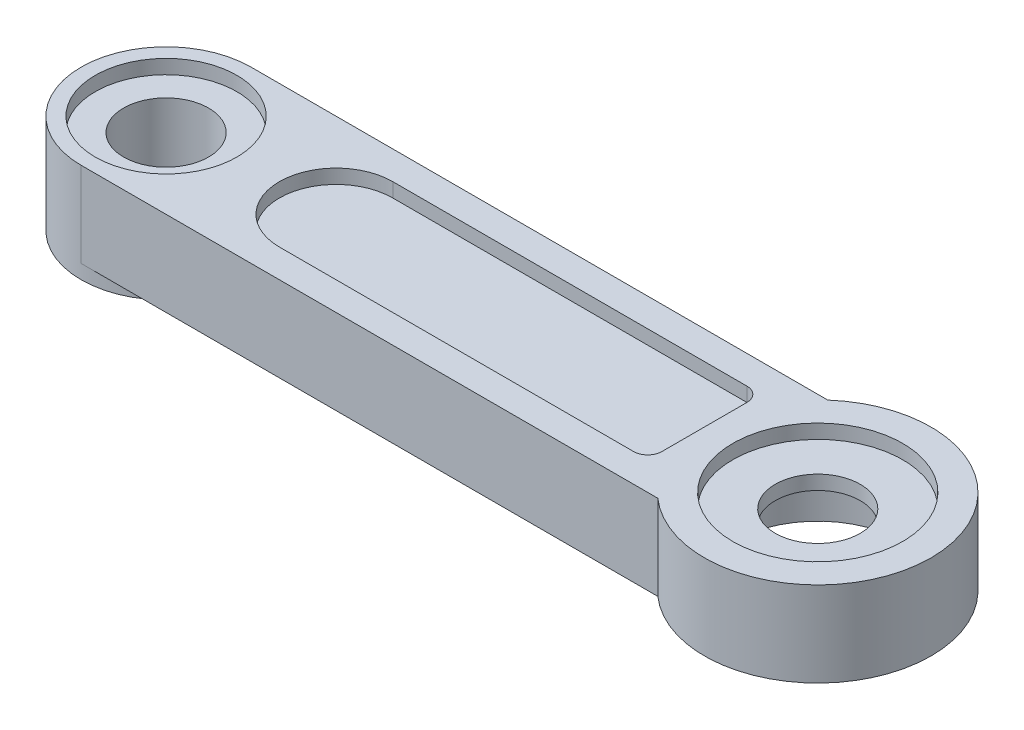
from build123d import *

# Parameters (mm, degrees)
SKETCH1_R           = 4
BOSS_EXTRUDE1_DEPTH = 3
SKETCH5_W           = 23
SKETCH5_H           = 6
BOSS_EXTRUDE2_DEPTH = 3
SKETCH2_R           = 3
CUT_EXTRUDE4_DEPTH  = 0.5
SKETCH7_R           = 1.5
CUT_EXTRUDE5_DEPTH  = 3.5
SKETCH8_R           = 3
CUT_EXTRUDE7_DEPTH  = 2
SKETCH9_R           = 3
BOSS_EXTRUDE3_DEPTH = 3
SKETCH10_R          = 2.5
CUT_EXTRUDE8_DEPTH  = 0.5
CUT_EXTRUDE10_DEPTH = 0.5
CUT_EXTRUDE11_DEPTH = 0.5
SKETCH11_R          = 3
BOSS_EXTRUDE5_DEPTH = 0.5
SKETCH15_R          = 1.5
CUT_EXTRUDE12_DEPTH = 4


with BuildPart() as part:
    # Sketch1 → Boss-Extrude1 (new body)
    with BuildSketch(Plane(origin=(0, 0, 0), x_dir=(1, 0, 0), z_dir=(0, 1, 0))):
        Circle(SKETCH1_R)
    extrude(amount=-BOSS_EXTRUDE1_DEPTH)

    # Sketch5 → Boss-Extrude2 (add)
    with BuildSketch(Plane(origin=(0, 0, 0), x_dir=(1, 0, 0), z_dir=(0, 1, 0))):
        with Locations((-11.5, 0)):
            Rectangle(SKETCH5_W, SKETCH5_H)
    extrude(amount=-BOSS_EXTRUDE2_DEPTH)

    # Sketch2 → Cut-Extrude4 (cut)
    with BuildSketch(Plane(origin=(0, 0, 0), x_dir=(1, 0, 0), z_dir=(0, 1, 0))):
        Circle(SKETCH2_R)
    extrude(amount=-CUT_EXTRUDE4_DEPTH, mode=Mode.SUBTRACT)

    # Sketch7 → Cut-Extrude5 (cut, through all)
    with BuildSketch(Plane(origin=(0, -0.5, 0), x_dir=(1, 0, 0), z_dir=(0, 1, 0))):
        Circle(SKETCH7_R)
    extrude(amount=-CUT_EXTRUDE5_DEPTH, mode=Mode.SUBTRACT)

    # Sketch8 → Cut-Extrude7 (cut)
    with BuildSketch(Plane.XZ.offset(3)):
        Circle(SKETCH8_R)
    extrude(amount=-CUT_EXTRUDE7_DEPTH, mode=Mode.SUBTRACT)

    # Sketch9 → Boss-Extrude3 (add)
    with BuildSketch(Plane(origin=(0, 0, 0), x_dir=(1, 0, 0), z_dir=(0, 1, 0))):
        with Locations((-23, 0)):
            Circle(SKETCH9_R)
    extrude(amount=-BOSS_EXTRUDE3_DEPTH)

    # Sketch10 → Cut-Extrude8 (cut)
    with BuildSketch(Plane(origin=(0, 0, 0), x_dir=(1, 0, 0), z_dir=(0, 1, 0))):
        with Locations((-23, 0)):
            Circle(SKETCH10_R)
    extrude(amount=-CUT_EXTRUDE8_DEPTH, mode=Mode.SUBTRACT)

    # Sketch12 → Cut-Extrude10 (cut)
    with BuildSketch(Plane(origin=(0, 0, 0), x_dir=(1, 0, 0), z_dir=(0, 1, 0))):
        with BuildLine():
            Line((-4.5, -2), (-17, -2))
            ThreePointArc((-17, -2), (-19, 0), (-17, 2))
            Line((-17, 2), (-4.5, 2))
            ThreePointArc((-4.5, 2), (-4.146446609, 1.853553391), (-4, 1.5))
            Line((-4, 1.5), (-4, -1.5))
            ThreePointArc((-4, -1.5), (-4.146446609, -1.853553391), (-4.5, -2))
        make_face()
    extrude(amount=-CUT_EXTRUDE10_DEPTH, mode=Mode.SUBTRACT)

    # Sketch13 → Cut-Extrude11 (cut)
    with BuildSketch(Plane.XZ.offset(3)):
        with BuildLine():
            Line((-4.5, -2), (-15, -2))
            ThreePointArc((-15, -2), (-17, 0), (-15, 2))
            Line((-15, 2), (-4.5, 2))
            ThreePointArc((-4.5, 2), (-4.146446609, 1.853553391), (-4, 1.5))
            Line((-4, 1.5), (-4, -1.5))
            ThreePointArc((-4, -1.5), (-4.146446609, -1.853553391), (-4.5, -2))
        make_face()
    extrude(amount=-CUT_EXTRUDE11_DEPTH, mode=Mode.SUBTRACT)

    # Sketch11 → Boss-Extrude5 (add)
    with BuildSketch(Plane(origin=(0, -3, 0), x_dir=(1, 0, 0), z_dir=(0, 1, 0))):
        with Locations((-23, 0)):
            Circle(SKETCH11_R)
    extrude(amount=-BOSS_EXTRUDE5_DEPTH)

    # Sketch15 → Cut-Extrude12 (cut, through all)
    with BuildSketch(Plane(origin=(0, -0.5, 0), x_dir=(1, 0, 0), z_dir=(0, 1, 0))):
        with Locations((-23, 0)):
            Circle(SKETCH15_R)
    extrude(amount=-CUT_EXTRUDE12_DEPTH, mode=Mode.SUBTRACT)


solid = part.part
